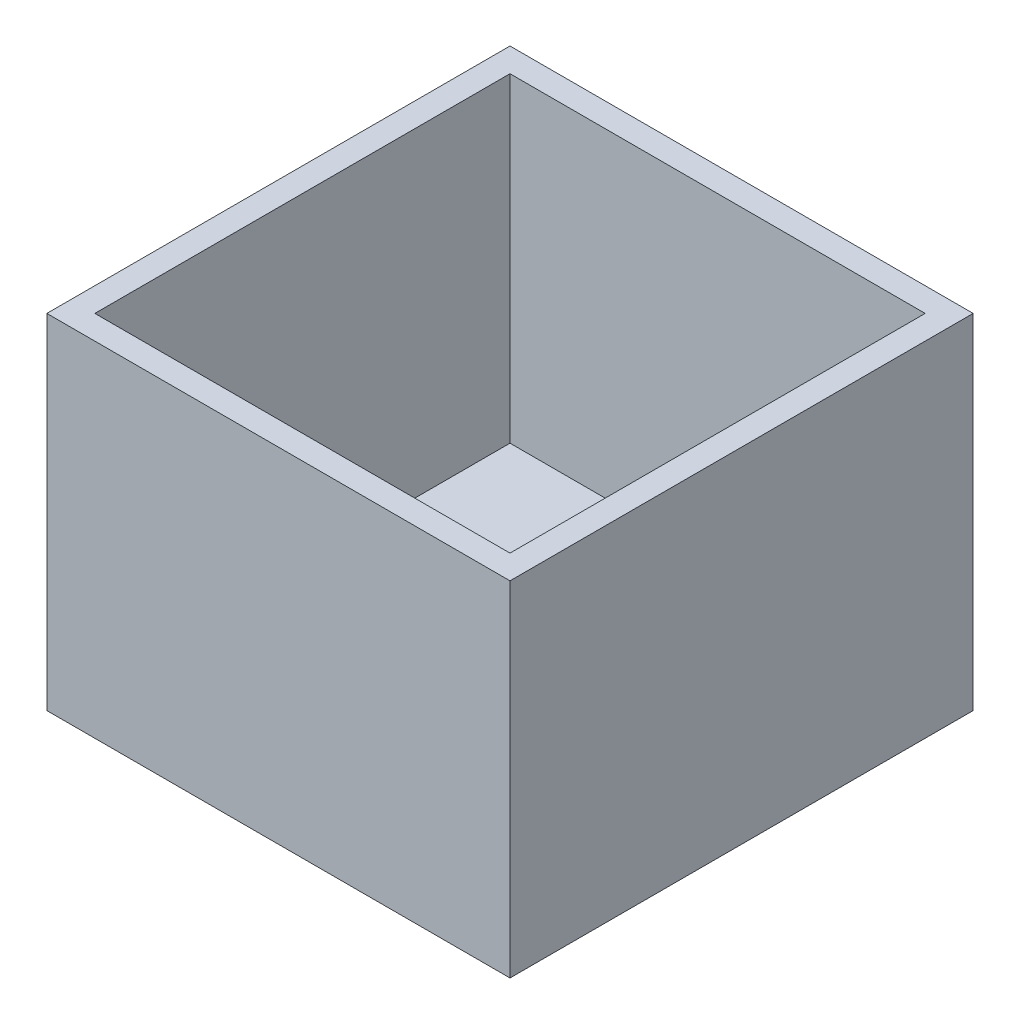
from build123d import *

# Parameters (mm, degrees)
SKETCH_1_W      = 57.9
SKETCH_1_H      = 57.9
EXTRUDE_1_DEPTH = 3
SKETCH_2_W      = 57.9
SKETCH_2_H      = 57.9
SKETCH_2_W_2    = 51.9
SKETCH_2_H_2    = 51.9
EXTRUDE_2_DEPTH = 40


with BuildPart() as part:
    # 草图1 → 凸台-拉伸1 (new body)
    with BuildSketch(Plane(origin=(0, 0, 0), x_dir=(1, 0, 0), z_dir=(0, 1, 0))):
        with Locations((25.95, 25.95)):
            Rectangle(SKETCH_1_W, SKETCH_1_H)
    extrude(amount=EXTRUDE_1_DEPTH)

    # 草图2 → 凸台-拉伸2 (add)
    with BuildSketch(Plane(origin=(0, 3, 0), x_dir=(1, 0, 0), z_dir=(0, 1, 0))):
        with Locations((25.95, 25.95)):
            Rectangle(SKETCH_2_W, SKETCH_2_H)
        with Locations((25.95, 25.95)):
            Rectangle(SKETCH_2_W_2, SKETCH_2_H_2, mode=Mode.SUBTRACT)
    extrude(amount=EXTRUDE_2_DEPTH)


solid = part.part
